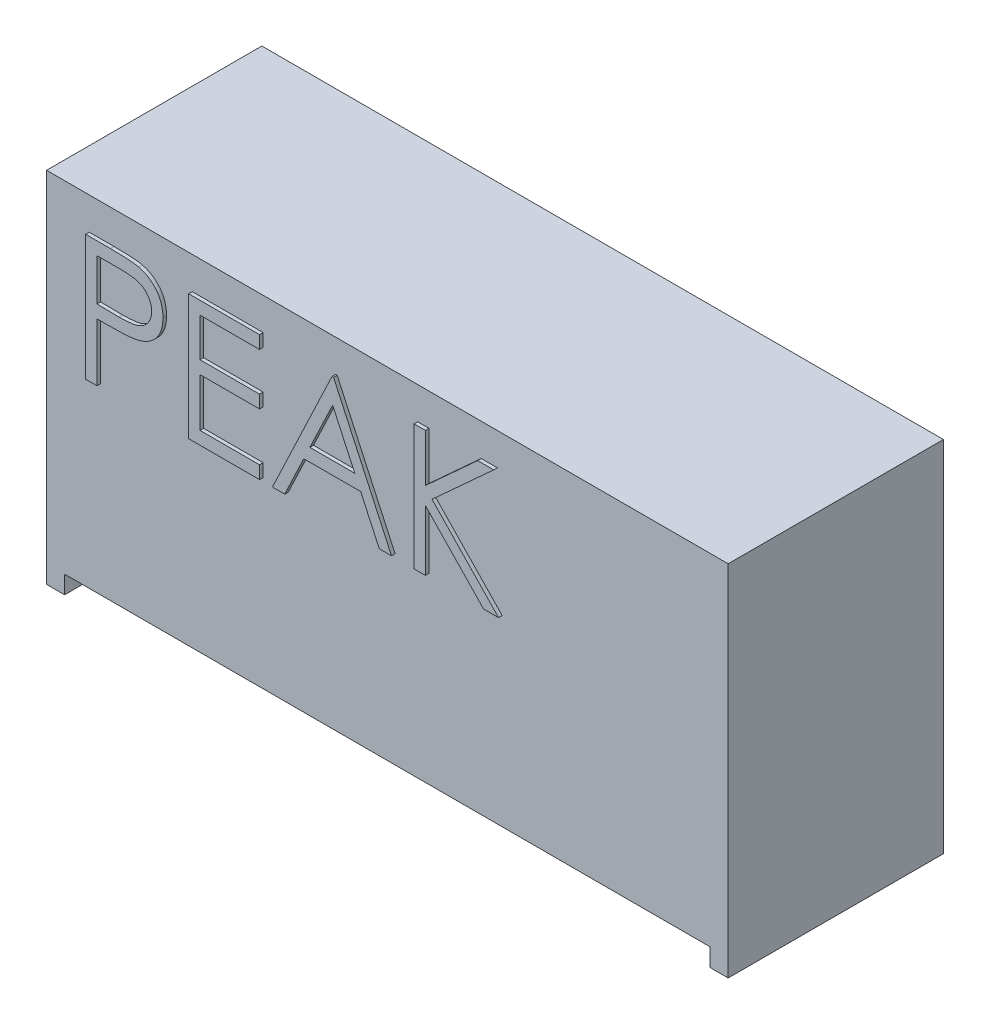
from build123d import *

# Parameters (mm, degrees)
EXTRUDE_1_DEPTH   = 6
EXTRUDE_2_DEPTH   = 0.1
EXTRUDE_2_2_DEPTH = 0.1
EXTRUDE_2_3_DEPTH = 0.1
EXTRUDE_2_4_DEPTH = 0.1


with BuildPart() as part:
    # Эскиз1 → Бобышка-Вытянуть1 (new body)
    with BuildSketch(Plane.XY):
        Polygon((-9, -5), (-9, -4.5), (9, -4.5), (9, -5), (9.5, -5), (9.5, 5), (-9.5, 5), (-9.5, -5), align=None)
    extrude(amount=EXTRUDE_1_DEPTH)


with BuildPart() as body_2:
    # Эскиз2 → Бобышка-Вытянуть2 (new body)
    with BuildSketch(Plane.XY.offset(6)):
        with BuildLine():
            Line((-8.310307946, 4.099799348), (-7.623909709, 4.099799348))
            add(Edge.make_bspline(
                [(-7.623909709, 4.099799348), (-7.576698803, 4.099747451), (-7.48624061, 4.099648016), (-7.356525554, 4.09663327), (-7.238715823, 4.092606578), (-7.133065442, 4.087024685), (-7.039249344, 4.080428095), (-6.957692044, 4.071176055), (-6.887752488, 4.06151576), (-6.845846038, 4.051694353), (-6.826734228, 4.047215213)],
                knots=[0, 0, 0, 0, 0.000141628, 0.000271366, 0.00038923, 0.000495248, 0.00058876, 0.000671296, 0.000741499, 0.00080036, 0.00080036, 0.00080036, 0.00080036], degree=3))
            add(Edge.make_bspline(
                [(-6.826734228, 4.047215213), (-6.802540695, 4.040593263), (-6.754723717, 4.027505402), (-6.685822674, 4.001291678), (-6.620268829, 3.970209513), (-6.55783727, 3.934785573), (-6.499295187, 3.893500009), (-6.443769146, 3.848026391), (-6.391749166, 3.797314823), (-6.343527774, 3.741934083), (-6.299242976, 3.682813873), (-6.261113294, 3.619071643), (-6.229186067, 3.55178034), (-6.201802795, 3.480986768), (-6.182094341, 3.406096445), (-6.167247441, 3.327629732), (-6.157823813, 3.245595042), (-6.156921252, 3.189535175), (-6.156461792, 3.160997264)],
                knots=[0, 0, 0, 0, 7.5216e-05, 0.00014866, 0.000220794, 0.000292713, 0.000363707, 0.000435434, 0.000507823, 0.000581364, 0.000655543, 0.000729131, 0.000803767, 0.000878771, 0.000956497, 0.001035702, 0.001118238, 0.001203821, 0.001203821, 0.001203821, 0.001203821], degree=3))
            add(Edge.make_bspline(
                [(-6.156461792, 3.160997264), (-6.156883217, 3.132219488), (-6.157707763, 3.075913824), (-6.167604048, 2.993541035), (-6.18093424, 2.914822645), (-6.201431292, 2.839933195), (-6.228276965, 2.769317424), (-6.259769018, 2.701896192), (-6.297752549, 2.63881652), (-6.341397378, 2.579849403), (-6.389948973, 2.524939491), (-6.443201911, 2.474484696), (-6.500941203, 2.428780358), (-6.562983352, 2.387724014), (-6.6299332, 2.352267735), (-6.700775354, 2.32051043), (-6.77612557, 2.293839369), (-6.828268084, 2.279809308), (-6.8547791, 2.27267595)],
                knots=[0, 0, 0, 0, 8.6284e-05, 0.00016882, 0.000248587, 0.000325638, 0.000401297, 0.000474998, 0.000548586, 0.000621785, 0.0006948, 0.0007682, 0.000841564, 0.000915458, 0.000991056, 0.00106858, 0.00114819, 0.001230532, 0.001230532, 0.001230532, 0.001230532], degree=3))
            add(Edge.make_bspline(
                [(-6.8547791, 2.27267595), (-6.876706434, 2.268012969), (-6.924761461, 2.257793775), (-7.003904184, 2.246385318), (-7.09604957, 2.236647718), (-7.201071849, 2.22934658), (-7.318876754, 2.223096211), (-7.449528012, 2.218128118), (-7.593282089, 2.215398264), (-7.693553333, 2.215257471), (-7.745904901, 2.215183963)],
                knots=[0, 0, 0, 0, 6.7238e-05, 0.000147357, 0.000239727, 0.000345177, 0.000463135, 0.000593636, 0.000737393, 0.000894446, 0.000894446, 0.000894446, 0.000894446], degree=3))
            Line((-7.745904901, 2.215183963), (-7.996205382, 2.215183963))
            Line((-7.996205382, 2.215183963), (-7.996205382, 0.599799348))
            Line((-7.996205382, 0.599799348), (-8.310307946, 0.599799348))
            Line((-8.310307946, 0.599799348), (-8.310307946, 4.099799348))
        make_face()
        with BuildLine():
            Line((-7.996205382, 3.740824989), (-7.996205382, 2.574158322))
            Line((-7.996205382, 2.574158322), (-7.383424933, 2.566445982))
            add(Edge.make_bspline(
                [(-7.383424933, 2.566445982), (-7.353505008, 2.566430519), (-7.295745208, 2.566400667), (-7.212308984, 2.57038589), (-7.134899697, 2.574986423), (-7.063755122, 2.581722346), (-6.998843187, 2.591243604), (-6.940055658, 2.600855342), (-6.887848376, 2.614760704), (-6.826749174, 2.633483773), (-6.758665826, 2.665416389), (-6.684598278, 2.711766279), (-6.621827691, 2.770846987), (-6.567509395, 2.837274819), (-6.524403517, 2.911173948), (-6.492847524, 2.990242885), (-6.474306367, 3.073670734), (-6.471820173, 3.130758873), (-6.470564357, 3.159595021)],
                knots=[0, 0, 0, 0, 8.9746e-05, 0.000173253, 0.000250533, 0.00032239, 0.000387534, 0.00044736, 0.000500926, 0.000549486, 0.000638903, 0.000725641, 0.000810488, 0.000896226, 0.000982324, 0.00106604, 0.001150757, 0.001237226, 0.001237226, 0.001237226, 0.001237226], degree=3))
            add(Edge.make_bspline(
                [(-6.470564357, 3.159595021), (-6.471827003, 3.187733534), (-6.474336988, 3.243669416), (-6.492992851, 3.325648177), (-6.524342165, 3.403883881), (-6.56779876, 3.476856967), (-6.620539889, 3.543045771), (-6.681839233, 3.600542898), (-6.751552494, 3.6467646), (-6.816400725, 3.676597882), (-6.874001911, 3.694813158), (-6.924033871, 3.707557998), (-6.980524545, 3.717733604), (-7.043492325, 3.725973107), (-7.112449159, 3.733026568), (-7.187987474, 3.737812546), (-7.269821117, 3.740614002), (-7.326631688, 3.740752957), (-7.356081183, 3.740824989)],
                knots=[0, 0, 0, 0, 8.4371e-05, 0.000167719, 0.000250783, 0.000336277, 0.000421575, 0.000503926, 0.000587348, 0.000671427, 0.000717102, 0.000768457, 0.000826213, 0.000889178, 0.000958942, 0.001034123, 0.001116202, 0.001204546, 0.001204546, 0.001204546, 0.001204546], degree=3))
            Line((-7.356081183, 3.740824989), (-7.996205382, 3.740824989))
        make_face(mode=Mode.SUBTRACT)
    extrude(amount=EXTRUDE_2_DEPTH)


with BuildPart() as body_3:
    # Эскиз2 → Extrude 2 2 (new body)
    with BuildSketch(Plane.XY.offset(6)):
        Polygon((-5.438513074, 4.099799348), (-3.4641541, 4.099799348), (-3.4641541, 3.740824989), (-5.12441051, 3.740824989), (-5.12441051, 2.663901912), (-3.4641541, 2.663901912), (-3.4641541, 2.304927553), (-5.12441051, 2.304927553), (-5.12441051, 0.958773707), (-3.4641541, 0.958773707), (-3.4641541, 0.599799348), (-5.438513074, 0.599799348), align=None)
    extrude(amount=EXTRUDE_2_2_DEPTH)


with BuildPart() as body_4:
    # Эскиз2 → Extrude 2 3 (new body)
    with BuildSketch(Plane.XY.offset(6)):
        Polygon((-1.400051536, 4.099799348), (0.215333079, 0.599799348), (-0.126113235, 0.599799348), (-0.643541119, 1.72159422), (-2.230179741, 1.72159422), (-2.762331183, 0.599799348), (-3.105179741, 0.599799348), (-1.444923331, 4.099799348), align=None)
        Polygon((-1.425993042, 3.417607841), (-2.059807145, 2.080568578), (-0.809005863, 2.080568578), align=None, mode=Mode.SUBTRACT)
    extrude(amount=EXTRUDE_2_3_DEPTH)


with BuildPart() as body_5:
    # Эскиз2 → Extrude 2 4 (new body)
    with BuildSketch(Plane.XY.offset(6)):
        Polygon((0.843538208, 4.099799348), (1.157640772, 4.099799348), (1.157640772, 2.766966816), (2.616675227, 4.099799348), (3.064692054, 4.099799348), (1.344840291, 2.529286527), (3.199307438, 0.599799348), (2.780737727, 0.599799348), (1.157640772, 2.288801752), (1.157640772, 0.599799348), (0.843538208, 0.599799348), align=None)
    extrude(amount=EXTRUDE_2_4_DEPTH)


solid = Compound([part.part, body_2.part, body_3.part, body_4.part, body_5.part])
